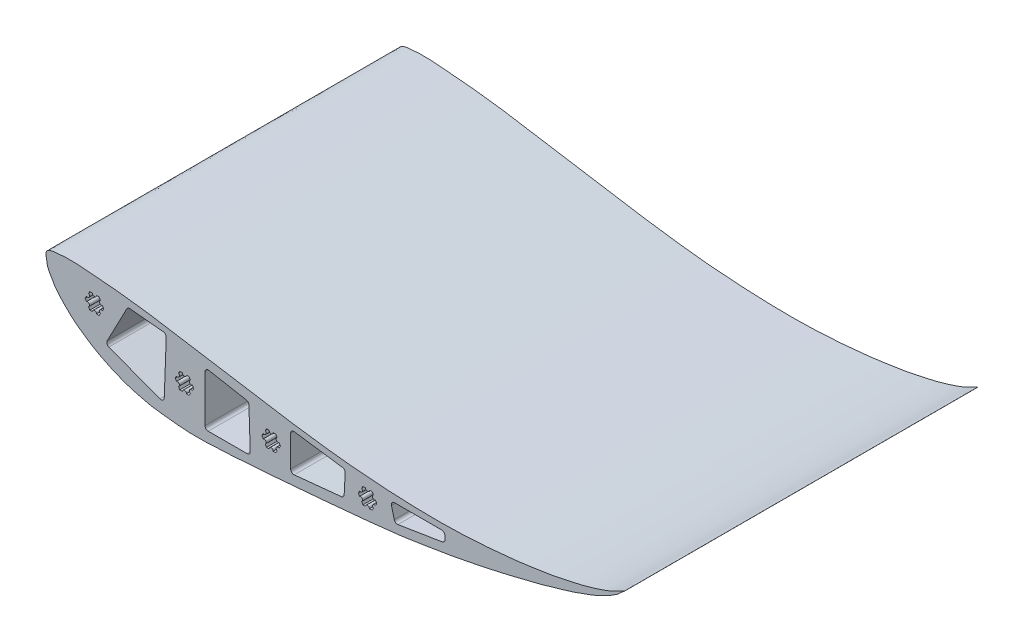
from build123d import *

# Parameters (mm, degrees)
BOSS_EXTRUDE1_DEPTH = 279.4
CUT_EXTRUDE3_DEPTH  = 381


with BuildPart() as part:
    # Sketch1 → Boss-Extrude1 (new body)
    with BuildSketch(Plane.XY):
        with BuildLine():
            add(Edge.make_bspline(
                [(-16.622525288, 91.56967272), (-16.794942994, 92.772317911), (-17.515788121, 97.582670832), (-2.852582554, 99.497127174), (9.154054709, 99.213304724), (23.433217875, 97.797752429), (34.6859051, 97.019819773), (46.592767258, 95.707761604), (58.472171701, 94.254609297), (72.666253463, 92.219697635), (88.15460255, 89.685431784), (109.15740223, 86.162485471), (130.076144789, 82.711728928), (150.055716296, 79.576696099), (168.256858053, 76.617688262), (186.559493812, 73.857794613), (206.695059336, 71.20791695), (225.195546149, 69.114961125), (244.068606399, 67.656695297), (262.594452449, 66.476567979), (282.222526995, 65.926744761), (300.99609332, 65.813021246), (318.737894065, 66.539084176), (334.742865336, 67.61277327), (348.252438633, 69.009944705), (359.067906447, 70.049570339), (367.896874578, 71.420704301), (377.007425502, 72.883057797), (386.227823421, 74.138373924), (395.367743176, 76.385575861), (403.564697097, 77.907582397), (410.735250399, 79.953005658), (417.114285798, 81.687412008), (422.732680223, 83.591992804), (427.164087313, 85.094079009), (431.171696898, 86.937153076), (434.607250511, 88.392786361), (443.123217376, 93.275688905), (437.255094337, 89.117703468), (435.279778464, 86.561175616), (431.573501891, 84.704524529), (428.464842726, 82.201032813), (424.134266462, 80.398696308), (419.425258521, 77.797857577), (414.105440345, 75.713007702), (408.77839072, 73.798734141), (403.684867312, 72.029145889), (396.961540144, 69.466067962), (387.343622202, 67.136732033), (376.830663922, 63.608926675), (365.24798357, 60.901656463), (354.754672426, 58.255886458), (344.650791699, 55.720154361), (336.670341174, 53.941801639), (329.235250959, 52.381752299), (321.327868225, 50.676833739), (310.892392252, 48.725728026), (298.426712372, 46.308387166), (284.136528131, 44.189578856), (268.909448728, 41.574011521), (251.075314715, 39.596728872), (229.386892765, 37.203012777), (203.753382466, 34.933554815), (177.46976253, 32.720447696), (150.443659112, 30.344574846), (123.02307167, 28.688327838), (101.004781565, 27.555963663), (84.804305156, 28.931500406), (75.72348416, 30.010523718), (67.270753352, 30.977463397), (60.250592801, 32.582425676), (53.932519662, 34.232006507), (47.114759922, 36.133551764), (41.43120503, 38.368275103), (36.428795002, 40.445297648), (32.069577899, 42.402430324), (27.662403595, 44.667790264), (23.104788958, 46.965799851), (18.73168781, 49.734821084), (12.723675127, 53.669846892), (5.809434759, 58.404883079), (-1.037305312, 65.077409289), (-6.513200759, 70.614178991), (-10.540658158, 76.008047875), (-12.880350205, 80.406543609), (-15.167480815, 84.128221175), (-16.123087236, 87.961419413), (-16.453570873, 90.391184614), (-16.622525288, 91.56967272)],
                knots=[0, 0, 0, 0, 0.003644297, 0.013581344, 0.034074787, 0.047557163, 0.057150579, 0.06958931, 0.084962672, 0.094623108, 0.114452008, 0.134073068, 0.161263036, 0.180794832, 0.197357561, 0.218965716, 0.238711125, 0.26090768, 0.277214827, 0.297940316, 0.318988728, 0.338651177, 0.356673355, 0.374539934, 0.388835783, 0.399172974, 0.408530924, 0.416784345, 0.428053881, 0.437617365, 0.446213781, 0.454125754, 0.460928052, 0.466918155, 0.472615005, 0.475771621, 0.480179638, 0.487250343, 0.490988881, 0.49507496, 0.498775568, 0.503369536, 0.507624299, 0.513322415, 0.520215853, 0.525455504, 0.531043662, 0.537088919, 0.5479516, 0.561953721, 0.571760074, 0.585151118, 0.595822817, 0.604354359, 0.61073386, 0.619595652, 0.629664863, 0.643953388, 0.659323518, 0.674864947, 0.692287919, 0.715453133, 0.743149301, 0.772805526, 0.797998576, 0.828023399, 0.858832685, 0.866768477, 0.87886578, 0.88746214, 0.893357873, 0.901377327, 0.907903322, 0.915486693, 0.920464298, 0.924856032, 0.930432876, 0.935970498, 0.940815755, 0.946613865, 0.958462559, 0.966932993, 0.97647901, 0.982815006, 0.98789669, 0.992067686, 0.996428904, 1, 1, 1, 1], degree=3))
        make_face()
    extrude(amount=BOSS_EXTRUDE1_DEPTH)

    # Sketch4 → Cut-Extrude3 (cut)
    with BuildSketch(Plane.XY.offset(279.4)):
        with BuildLine():
            Line((88.931300118, 66.243537573), (91.009974327, 66.243537573))
            ThreePointArc((91.009974327, 66.243537573), (92.597474327, 64.656037573), (94.184974327, 66.243537573))
            Line((94.184974327, 66.243537573), (96.263648536, 66.243537573))
            Line((96.263648536, 66.243537573), (97.302985641, 64.443352902))
            ThreePointArc((97.302985641, 64.443352902), (96.721920503, 62.274787243), (98.890486301, 61.693722626))
            Line((98.890486301, 61.693722626), (99.929823515, 59.893537766))
            Line((99.929823515, 59.893537766), (98.89048641, 58.093353094))
            ThreePointArc((98.89048641, 58.093353094), (96.721921082, 57.512287766), (97.30298641, 55.343722437))
            Line((97.30298641, 55.343722437), (96.263649306, 53.543537766))
            Line((96.263649306, 53.543537766), (94.184975096, 53.543537766))
            ThreePointArc((94.184975096, 53.543537766), (92.597475, 55.131037573), (91.009975096, 53.543537573))
            Line((91.009975096, 53.543537573), (88.931300887, 53.543537573))
            Line((88.931300887, 53.543537573), (87.891963673, 55.343722182))
            ThreePointArc((87.891963673, 55.343722182), (88.47302887, 57.512287545), (86.304463507, 58.093352743))
            Line((86.304463507, 58.093352743), (85.265126293, 59.893537351))
            Line((85.265126293, 59.893537351), (86.304463288, 61.693722086))
            ThreePointArc((86.304463288, 61.693722086), (88.473028582, 62.274787545), (87.891963122, 64.443352839))
            Line((87.891963122, 64.443352839), (88.931300118, 66.243537573))
        make_face()
        with BuildLine():
            Line((17.811300118, 85.293537573), (19.889974327, 85.293537573))
            ThreePointArc((19.889974327, 85.293537573), (21.477474327, 83.706037573), (23.064974327, 85.293537573))
            Line((23.064974327, 85.293537573), (25.143648536, 85.293537573))
            Line((25.143648536, 85.293537573), (26.182985641, 83.493352902))
            ThreePointArc((26.182985641, 83.493352902), (25.601920503, 81.324787243), (27.770486301, 80.743722626))
            Line((27.770486301, 80.743722626), (28.809823515, 78.943537766))
            Line((28.809823515, 78.943537766), (27.77048641, 77.143353094))
            ThreePointArc((27.77048641, 77.143353094), (25.601921082, 76.562287766), (26.18298641, 74.393722437))
            Line((26.18298641, 74.393722437), (25.143649306, 72.593537766))
            Line((25.143649306, 72.593537766), (23.064975096, 72.593537766))
            ThreePointArc((23.064975096, 72.593537766), (21.477475, 74.181037573), (19.889975096, 72.593537573))
            Line((19.889975096, 72.593537573), (17.811300887, 72.593537573))
            Line((17.811300887, 72.593537573), (16.771963673, 74.393722182))
            ThreePointArc((16.771963673, 74.393722182), (17.35302887, 76.562287545), (15.184463507, 77.143352743))
            Line((15.184463507, 77.143352743), (14.145126293, 78.943537351))
            Line((14.145126293, 78.943537351), (15.184463288, 80.743722086))
            ThreePointArc((15.184463288, 80.743722086), (17.353028582, 81.324787545), (16.771963122, 83.493352839))
            Line((16.771963122, 83.493352839), (17.811300118, 85.293537573))
        make_face()
        with BuildLine():
            Line((233.711300118, 59.893537573), (235.789974327, 59.893537573))
            ThreePointArc((235.789974327, 59.893537573), (237.377474327, 58.306037573), (238.964974327, 59.893537573))
            Line((238.964974327, 59.893537573), (241.043648536, 59.893537573))
            Line((241.043648536, 59.893537573), (242.082985641, 58.093352902))
            ThreePointArc((242.082985641, 58.093352902), (241.501920503, 55.924787243), (243.670486301, 55.343722626))
            Line((243.670486301, 55.343722626), (244.709823515, 53.543537766))
            Line((244.709823515, 53.543537766), (243.67048641, 51.743353094))
            ThreePointArc((243.67048641, 51.743353094), (241.501921082, 51.162287766), (242.08298641, 48.993722437))
            Line((242.08298641, 48.993722437), (241.043649306, 47.193537766))
            Line((241.043649306, 47.193537766), (238.964975096, 47.193537766))
            ThreePointArc((238.964975096, 47.193537766), (237.377475, 48.781037573), (235.789975096, 47.193537573))
            Line((235.789975096, 47.193537573), (233.711300887, 47.193537573))
            Line((233.711300887, 47.193537573), (232.671963673, 48.993722182))
            ThreePointArc((232.671963673, 48.993722182), (233.25302887, 51.162287545), (231.084463507, 51.743352743))
            Line((231.084463507, 51.743352743), (230.045126293, 53.543537351))
            Line((230.045126293, 53.543537351), (231.084463288, 55.343722086))
            ThreePointArc((231.084463288, 55.343722086), (233.253028582, 55.924787545), (232.671963122, 58.093352839))
            Line((232.671963122, 58.093352839), (233.711300118, 59.893537573))
        make_face()
        with BuildLine():
            Line((157.511300118, 61.163537573), (159.589974327, 61.163537573))
            ThreePointArc((159.589974327, 61.163537573), (161.177474327, 59.576037573), (162.764974327, 61.163537573))
            Line((162.764974327, 61.163537573), (164.843648536, 61.163537573))
            Line((164.843648536, 61.163537573), (165.882985641, 59.363352902))
            ThreePointArc((165.882985641, 59.363352902), (165.301920503, 57.194787243), (167.470486301, 56.613722626))
            Line((167.470486301, 56.613722626), (168.509823515, 54.813537766))
            Line((168.509823515, 54.813537766), (167.47048641, 53.013353094))
            ThreePointArc((167.47048641, 53.013353094), (165.301921082, 52.432287766), (165.88298641, 50.263722437))
            Line((165.88298641, 50.263722437), (164.843649306, 48.463537766))
            Line((164.843649306, 48.463537766), (162.764975096, 48.463537766))
            ThreePointArc((162.764975096, 48.463537766), (161.177475, 50.051037573), (159.589975096, 48.463537573))
            Line((159.589975096, 48.463537573), (157.511300887, 48.463537573))
            Line((157.511300887, 48.463537573), (156.471963673, 50.263722182))
            ThreePointArc((156.471963673, 50.263722182), (157.05302887, 52.432287545), (154.884463507, 53.013352743))
            Line((154.884463507, 53.013352743), (153.845126293, 54.813537351))
            Line((153.845126293, 54.813537351), (154.884463288, 56.613722086))
            ThreePointArc((154.884463288, 56.613722086), (157.053028582, 57.194787545), (156.471963122, 59.363352839))
            Line((156.471963122, 59.363352839), (157.511300118, 61.163537573))
        make_face()
        with BuildLine():
            Line((31.501207482, 58.37669779), (47.032113751, 88.081016492))
            ThreePointArc((47.032113751, 88.081016492), (48.076445172, 89.139261035), (49.534182489, 89.431684603))
            Line((49.534182489, 89.431684603), (75.93058222, 86.808602351))
            ThreePointArc((75.93058222, 86.808602351), (77.593752589, 85.950453195), (78.217633108, 84.185990458))
            Line((78.217633108, 84.185990458), (76.631821885, 41.843273018))
            ThreePointArc((76.631821885, 41.843273018), (75.497981954, 39.821894696), (73.194863199, 39.56265096))
            Line((73.194863199, 39.56265096), (32.853368422, 54.824131949))
            ThreePointArc((32.853368422, 54.824131949), (31.378241648, 56.296285615), (31.501207482, 58.37669779))
        make_face()
        with BuildLine():
            Line((111.858309541, 78.393902518), (141.485442222, 72.962296795))
            ThreePointArc((141.485442222, 72.962296795), (142.950940478, 72.12274223), (143.565962065, 70.549756072))
            Line((143.565962065, 70.549756072), (144.628770085, 39.112135773))
            ThreePointArc((144.628770085, 39.112135773), (143.916361615, 37.260866924), (142.090220332, 36.486315313))
            Line((142.090220332, 36.486315313), (111.400279631, 36.486315313))
            ThreePointArc((111.400279631, 36.486315313), (109.604228407, 37.230264089), (108.860279631, 39.026315313))
            Line((108.860279631, 39.026315313), (108.860279631, 75.895541334))
            ThreePointArc((108.860279631, 75.895541334), (109.774210132, 77.846822448), (111.858309541, 78.393902518))
        make_face()
        with BuildLine():
            Line((179.473393864, 70.165192722), (217.50482476, 64.769576264))
            ThreePointArc((217.50482476, 64.769576264), (219.108331349, 63.86995645), (219.68467301, 62.123995546))
            Line((219.68467301, 62.123995546), (218.890378913, 46.71578744))
            ThreePointArc((218.890378913, 46.71578744), (218.192789678, 45.094545708), (216.607247121, 44.319232678))
            Line((216.607247121, 44.319232678), (179.370110323, 40.58420072))
            ThreePointArc((179.370110323, 40.58420072), (177.412540188, 41.227973149), (176.576610312, 43.111519011))
            Line((176.576610312, 43.111519011), (176.576610312, 67.650375533))
            ThreePointArc((176.576610312, 67.650375533), (177.451472213, 69.568425352), (179.473393864, 70.165192722))
        make_face()
        with BuildLine():
            Line((258.751236774, 61.163537573), (296.003687002, 61.163537573))
            ThreePointArc((296.003687002, 61.163537573), (297.799738226, 60.419588797), (298.543687002, 58.623537573))
            Line((298.543687002, 58.623537573), (298.543687002, 55.707363059))
            ThreePointArc((298.543687002, 55.707363059), (297.937199117, 54.060204626), (296.407363457, 53.199645906))
            Line((296.407363457, 53.199645906), (261.377375447, 47.560739881))
            ThreePointArc((261.377375447, 47.560739881), (259.584877656, 47.941775277), (258.515299797, 49.429807368))
            Line((258.515299797, 49.429807368), (256.292837579, 57.984887907))
            ThreePointArc((256.292837579, 57.984887907), (256.742036666, 60.177472876), (258.751236774, 61.163537573))
        make_face()
    extrude(amount=-CUT_EXTRUDE3_DEPTH, mode=Mode.SUBTRACT)


solid = part.part
